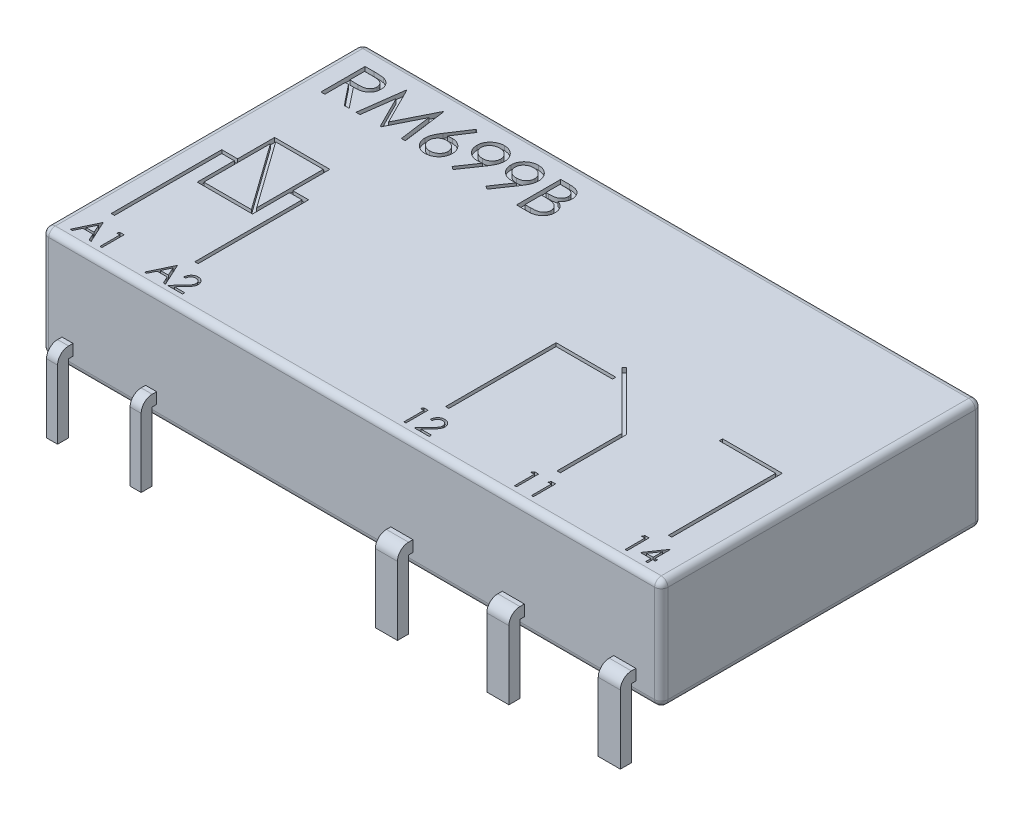
from build123d import *

# Parameters (mm, degrees)
SKETCH2_W             = 28
SKETCH2_H             = 14.5
BOSS_EXTRUDE1_DEPTH   = 5
SKETCH4_W             = 0.5
SKETCH4_H             = 0.5
BOSS_EXTRUDE2_DEPTH   = 3.1
BOSS_EXTRUDE2_2_DEPTH = 3.1
SKETCH4_W_2           = 1
BOSS_EXTRUDE2_3_DEPTH = 3.1
BOSS_EXTRUDE2_4_DEPTH = 3.1
BOSS_EXTRUDE2_5_DEPTH = 3.1
FILLET3_R             = 0.3
CUT_EXTRUDE1_DEPTH    = 0.2
CUT_EXTRUDE2_DEPTH    = 0.2
SKETCH8_W             = 1
SKETCH8_H             = 0.5
SKETCH8_W_2           = 0.5
BOSS_EXTRUDE3_DEPTH   = 0.7
FILLET4_R             = 0.5


with BuildPart() as part:
    # Sketch2 → Boss-Extrude1 (new body)
    with BuildSketch(Plane(origin=(0, 0, 0), x_dir=(1, 0, 0), z_dir=(0, 1, 0))):
        with Locations((0, 7.7)):
            Rectangle(SKETCH2_W, SKETCH2_H)
    extrude(amount=BOSS_EXTRUDE1_DEPTH)

    # Fillet3
    fillet3_edges = [part.edges().sort_by_distance(p)[0] for p in [
        (14, 5, -7.7),
        (0, 5, -14.95),
        (-14, 5, -7.7),
        (0, 0, -14.95),
        (14, 0, -7.7),
        (0, 0, -0.45),
        (-14, 0, -7.7),
        (0, 5, -0.45),
        (-14, 2.5, -14.95),
        (14, 2.5, -14.95),
        (14, 2.5, -0.45),
        (-14, 2.5, -0.45),
    ]]
    fillet(fillet3_edges, radius=FILLET3_R)

    # Sketch6 → Cut-Extrude1 (cut)
    with BuildSketch(Plane(origin=(0, 5, 0), x_dir=(1, 0, 0), z_dir=(0, 1, 0))):
        Polygon((-12.74882859, 1.958392306), (-12.287290129, 0.958392306), (-12.384846219, 0.958392306), (-12.532682757, 1.278905127), (-12.986008077, 1.278905127), (-13.138051347, 0.958392306), (-13.236008077, 0.958392306), (-12.761649103, 1.958392306), align=None)
        Polygon((-12.756240449, 1.763480447), (-12.937330193, 1.381469229), (-12.579958398, 1.381469229), align=None, mode=Mode.SUBTRACT)
        Polygon((-11.985006475, 1.958392306), (-11.800110642, 1.958392306), (-11.800110642, 0.958392306), (-11.889854231, 0.958392306), (-11.889854231, 1.855828204), (-12.043700385, 1.855828204), align=None)
        Polygon((-9.389854231, 1.958392306), (-8.92831577, 0.958392306), (-9.02587186, 0.958392306), (-9.173708398, 1.278905127), (-9.627033719, 1.278905127), (-9.779076988, 0.958392306), (-9.877033719, 0.958392306), (-9.402674744, 1.958392306), align=None)
        Polygon((-9.39726609, 1.763480447), (-9.578355834, 1.381469229), (-9.220984039, 1.381469229), align=None, mode=Mode.SUBTRACT)
        with BuildLine():
            Line((-8.710367052, 1.650699998), (-8.800110642, 1.650699998))
            add(Edge.make_bspline(
                [(-8.800110642, 1.650699998), (-8.799525741, 1.662605966), (-8.798377011, 1.685988971), (-8.7929975, 1.720081515), (-8.785300106, 1.752668601), (-8.774416834, 1.783488576), (-8.760900754, 1.812813949), (-8.744692175, 1.84052824), (-8.725493932, 1.866525722), (-8.70372058, 1.890565392), (-8.680072397, 1.912618983), (-8.654556414, 1.931663338), (-8.627743549, 1.947754102), (-8.59971515, 1.961205885), (-8.570154989, 1.971302984), (-8.539331315, 1.978794881), (-8.507108704, 1.983302408), (-8.485154412, 1.983786918), (-8.473988847, 1.984033332)],
                knots=[0, 0, 0, 0, 3.5738e-05, 7.0188e-05, 0.000103373, 0.000136064, 0.000168061, 0.000200116, 0.000232208, 0.000264831, 0.000297294, 0.000329065, 0.000360156, 0.00039098, 0.000422149, 0.000453681, 0.000486034, 0.000519517, 0.000519517, 0.000519517, 0.000519517], degree=3))
            add(Edge.make_bspline(
                [(-8.473988847, 1.984033332), (-8.463023683, 1.98377663), (-8.441477527, 1.98327222), (-8.410031237, 1.978940497), (-8.380094867, 1.972156043), (-8.351726934, 1.962637352), (-8.325153773, 1.949841802), (-8.30017576, 1.934471076), (-8.276495528, 1.916693982), (-8.255179305, 1.895764321), (-8.235605568, 1.873420782), (-8.218719209, 1.849567095), (-8.204258305, 1.824930157), (-8.192204682, 1.799322099), (-8.1833315, 1.772501805), (-8.176594869, 1.744859747), (-8.172787036, 1.716109801), (-8.17220263, 1.696650785), (-8.171905513, 1.686757691)],
                knots=[0, 0, 0, 0, 3.2882e-05, 6.4613e-05, 9.5033e-05, 0.00012487, 0.000154169, 0.000183303, 0.000212751, 0.000242786, 0.000272749, 0.000301764, 0.000330315, 0.000358367, 0.000386493, 0.000414917, 0.000443616, 0.000473296, 0.000473296, 0.000473296, 0.000473296], degree=3))
            add(Edge.make_bspline(
                [(-8.171905513, 1.686757691), (-8.172389303, 1.672829738), (-8.173348392, 1.645218248), (-8.181552499, 1.604642573), (-8.194365788, 1.565330168), (-8.209793604, 1.533690939), (-8.22535716, 1.508195655), (-8.239382162, 1.487204596), (-8.255800679, 1.464603034), (-8.274851679, 1.440466652), (-8.296141071, 1.414606393), (-8.319861689, 1.38703788), (-8.346182684, 1.358045946), (-8.364656541, 1.338244346), (-8.374229231, 1.327983652)],
                knots=[0, 0, 0, 0, 4.1748e-05, 8.2763e-05, 0.000123686, 0.000165526, 0.000187994, 0.000213273, 0.000241241, 0.000271777, 0.000305505, 0.000341726, 0.000380871, 0.000422969, 0.000422969, 0.000422969, 0.000422969], degree=3))
            Line((-8.374229231, 1.327983652), (-8.624429552, 1.060956409))
            Line((-8.624429552, 1.060956409), (-8.159085001, 1.060956409))
            Line((-8.159085001, 1.060956409), (-8.159085001, 0.958392306))
            Line((-8.159085001, 0.958392306), (-8.83857218, 0.958392306))
            Line((-8.83857218, 0.958392306), (-8.450751667, 1.372254486))
            add(Edge.make_bspline(
                [(-8.450751667, 1.372254486), (-8.441309414, 1.382111145), (-8.423172778, 1.401043769), (-8.397520613, 1.428684615), (-8.374480902, 1.454327341), (-8.353904504, 1.477923498), (-8.336237788, 1.499818231), (-8.320560007, 1.519302432), (-8.30799841, 1.537232275), (-8.29436544, 1.558015308), (-8.281161445, 1.583390256), (-8.269815058, 1.614399881), (-8.26289653, 1.646321953), (-8.262066577, 1.667893964), (-8.261649103, 1.67874487)],
                knots=[0, 0, 0, 0, 4.0948e-05, 7.8653e-05, 0.000113123, 0.000144368, 0.000172557, 0.000197523, 0.000219366, 0.000238203, 0.000272071, 0.000304896, 0.000337034, 0.00036956, 0.00036956, 0.00036956, 0.00036956], degree=3))
            add(Edge.make_bspline(
                [(-8.261649103, 1.67874487), (-8.261830744, 1.685568127), (-8.262188723, 1.699015456), (-8.265348065, 1.718731387), (-8.270122495, 1.737749905), (-8.276963997, 1.75612951), (-8.285994495, 1.773685411), (-8.296986889, 1.790438977), (-8.309669764, 1.806635824), (-8.324341555, 1.821822481), (-8.340459132, 1.835731396), (-8.357486061, 1.848052564), (-8.375500376, 1.858349452), (-8.394426126, 1.866790452), (-8.414210545, 1.873411989), (-8.434891901, 1.878000155), (-8.456413049, 1.880880864), (-8.471108333, 1.881270628), (-8.478596219, 1.881469229)],
                knots=[0, 0, 0, 0, 2.0457e-05, 4.0317e-05, 5.9751e-05, 7.9211e-05, 9.9011e-05, 0.000118847, 0.000139245, 0.000160638, 0.000182083, 0.000203042, 0.00022359, 0.000244214, 0.000265119, 0.000286064, 0.000307681, 0.00033014, 0.00033014, 0.00033014, 0.00033014], degree=3))
            add(Edge.make_bspline(
                [(-8.478596219, 1.881469229), (-8.486416456, 1.881264934), (-8.501774112, 1.880863733), (-8.524322408, 1.878057257), (-8.54583263, 1.873215589), (-8.566358888, 1.866593682), (-8.585935912, 1.858176953), (-8.604468496, 1.847693598), (-8.621915036, 1.835184028), (-8.638308328, 1.821001012), (-8.653412322, 1.805210269), (-8.666682858, 1.787607422), (-8.678278291, 1.768513875), (-8.688395215, 1.747981146), (-8.696611126, 1.725822924), (-8.702889169, 1.702117865), (-8.70785684, 1.676968899), (-8.709516417, 1.659601732), (-8.710367052, 1.650699998)],
                knots=[0, 0, 0, 0, 2.3459e-05, 4.6069e-05, 6.8036e-05, 8.9512e-05, 0.000110686, 0.000131856, 0.000153256, 0.000174984, 0.000196805, 0.000218681, 0.000240978, 0.000263733, 0.000287249, 0.000311741, 0.000337238, 0.00036405, 0.00036405, 0.00036405, 0.00036405], degree=3))
        make_face()
        Polygon((1.758583269, 1.958392306), (1.943479102, 1.958392306), (1.943479102, 0.958392306), (1.853735512, 0.958392306), (1.853735512, 1.855828204), (1.699889358, 1.855828204), align=None)
        with BuildLine():
            Line((2.443479102, 1.650699998), (2.353735512, 1.650699998))
            add(Edge.make_bspline(
                [(2.353735512, 1.650699998), (2.354320413, 1.662605966), (2.355469143, 1.685988971), (2.360848654, 1.720081515), (2.368546048, 1.752668601), (2.37942932, 1.783488576), (2.392945399, 1.812813949), (2.409153979, 1.84052824), (2.428352222, 1.866525722), (2.450125574, 1.890565392), (2.473773757, 1.912618983), (2.49928974, 1.931663338), (2.526102605, 1.947754102), (2.554131004, 1.961205885), (2.583691165, 1.971302984), (2.614514839, 1.978794881), (2.646737449, 1.983302408), (2.668691741, 1.983786918), (2.679857307, 1.984033332)],
                knots=[0, 0, 0, 0, 3.5738e-05, 7.0188e-05, 0.000103373, 0.000136064, 0.000168061, 0.000200116, 0.000232208, 0.000264831, 0.000297294, 0.000329065, 0.000360156, 0.00039098, 0.000422149, 0.000453681, 0.000486034, 0.000519517, 0.000519517, 0.000519517, 0.000519517], degree=3))
            add(Edge.make_bspline(
                [(2.679857307, 1.984033332), (2.690822471, 1.98377663), (2.712368627, 1.98327222), (2.743814917, 1.978940497), (2.773751286, 1.972156043), (2.80211922, 1.962637352), (2.828692381, 1.949841802), (2.853670394, 1.934471076), (2.877350625, 1.916693982), (2.898666849, 1.895764321), (2.918240586, 1.873420782), (2.935126945, 1.849567095), (2.949587849, 1.824930157), (2.961641472, 1.799322099), (2.970514654, 1.772501805), (2.977251285, 1.744859747), (2.981059117, 1.716109801), (2.981643524, 1.696650785), (2.98194064, 1.686757691)],
                knots=[0, 0, 0, 0, 3.2882e-05, 6.4613e-05, 9.5033e-05, 0.00012487, 0.000154169, 0.000183303, 0.000212751, 0.000242786, 0.000272749, 0.000301764, 0.000330315, 0.000358367, 0.000386493, 0.000414917, 0.000443616, 0.000473296, 0.000473296, 0.000473296, 0.000473296], degree=3))
            add(Edge.make_bspline(
                [(2.98194064, 1.686757691), (2.981456851, 1.672829738), (2.980497762, 1.645218248), (2.972293655, 1.604642573), (2.959480366, 1.565330168), (2.944052549, 1.533690939), (2.928488994, 1.508195655), (2.914463992, 1.487204596), (2.898045474, 1.464603034), (2.878994475, 1.440466652), (2.857705083, 1.414606393), (2.833984465, 1.38703788), (2.80766347, 1.358045946), (2.789189613, 1.338244346), (2.779616923, 1.327983652)],
                knots=[0, 0, 0, 0, 4.1748e-05, 8.2763e-05, 0.000123686, 0.000165526, 0.000187994, 0.000213273, 0.000241241, 0.000271777, 0.000305505, 0.000341726, 0.000380871, 0.000422969, 0.000422969, 0.000422969, 0.000422969], degree=3))
            Line((2.779616923, 1.327983652), (2.529416602, 1.060956409))
            Line((2.529416602, 1.060956409), (2.994761153, 1.060956409))
            Line((2.994761153, 1.060956409), (2.994761153, 0.958392306))
            Line((2.994761153, 0.958392306), (2.315273974, 0.958392306))
            Line((2.315273974, 0.958392306), (2.703094487, 1.372254486))
            add(Edge.make_bspline(
                [(2.703094487, 1.372254486), (2.71253674, 1.382111145), (2.730673376, 1.401043769), (2.756325541, 1.428684615), (2.779365252, 1.454327341), (2.79994165, 1.477923498), (2.817608366, 1.499818231), (2.833286146, 1.519302432), (2.845847744, 1.537232275), (2.859480714, 1.558015308), (2.872684709, 1.583390256), (2.884031096, 1.614399881), (2.890949624, 1.646321953), (2.891779577, 1.667893964), (2.892197051, 1.67874487)],
                knots=[0, 0, 0, 0, 4.0948e-05, 7.8653e-05, 0.000113123, 0.000144368, 0.000172557, 0.000197523, 0.000219366, 0.000238203, 0.000272071, 0.000304896, 0.000337034, 0.00036956, 0.00036956, 0.00036956, 0.00036956], degree=3))
            add(Edge.make_bspline(
                [(2.892197051, 1.67874487), (2.89201541, 1.685568127), (2.891657431, 1.699015456), (2.888498089, 1.718731387), (2.883723659, 1.737749905), (2.876882156, 1.75612951), (2.867851659, 1.773685411), (2.856859265, 1.790438977), (2.84417639, 1.806635824), (2.829504599, 1.821822481), (2.813387021, 1.835731396), (2.796360093, 1.848052564), (2.778345777, 1.858349452), (2.759420028, 1.866790452), (2.739635608, 1.873411989), (2.718954253, 1.878000155), (2.697433105, 1.880880864), (2.682737821, 1.881270628), (2.675249935, 1.881469229)],
                knots=[0, 0, 0, 0, 2.0457e-05, 4.0317e-05, 5.9751e-05, 7.9211e-05, 9.9011e-05, 0.000118847, 0.000139245, 0.000160638, 0.000182083, 0.000203042, 0.00022359, 0.000244214, 0.000265119, 0.000286064, 0.000307681, 0.00033014, 0.00033014, 0.00033014, 0.00033014], degree=3))
            add(Edge.make_bspline(
                [(2.675249935, 1.881469229), (2.667429697, 1.881264934), (2.652072041, 1.880863733), (2.629523746, 1.878057257), (2.608013524, 1.873215589), (2.587487266, 1.866593682), (2.567910242, 1.858176953), (2.549377658, 1.847693598), (2.531931118, 1.835184028), (2.515537825, 1.821001012), (2.500433831, 1.805210269), (2.487163295, 1.787607422), (2.475567863, 1.768513875), (2.465450939, 1.747981146), (2.457235027, 1.725822924), (2.450956985, 1.702117865), (2.445989314, 1.676968899), (2.444329737, 1.659601732), (2.443479102, 1.650699998)],
                knots=[0, 0, 0, 0, 2.3459e-05, 4.6069e-05, 6.8036e-05, 8.9512e-05, 0.000110686, 0.000131856, 0.000153256, 0.000174984, 0.000196805, 0.000218681, 0.000240978, 0.000263733, 0.000287249, 0.000311741, 0.000337238, 0.00036405, 0.00036405, 0.00036405, 0.00036405], degree=3))
        make_face()
        Polygon((6.758583269, 1.958392306), (6.943479102, 1.958392306), (6.943479102, 0.958392306), (6.853735512, 0.958392306), (6.853735512, 1.855828204), (6.699889358, 1.855828204), align=None)
        Polygon((7.527814038, 1.958392306), (7.712709871, 1.958392306), (7.712709871, 0.958392306), (7.622966281, 0.958392306), (7.622966281, 1.855828204), (7.469120128, 1.855828204), align=None)
        Polygon((11.758583269, 1.958392306), (11.943479102, 1.958392306), (11.943479102, 0.958392306), (11.853735512, 0.958392306), (11.853735512, 1.855828204), (11.699889358, 1.855828204), align=None)
        Polygon((12.861147371, 1.984033332), (12.879376538, 1.984033332), (12.879376538, 1.291725639), (12.994761153, 1.291725639), (12.994761153, 1.189161537), (12.879376538, 1.189161537), (12.879376538, 0.958392306), (12.789632948, 0.958392306), (12.789632948, 1.189161537), (12.315273974, 1.189161537), align=None)
        Polygon((12.789632948, 1.291725639), (12.789632948, 1.726020511), (12.491556025, 1.291725639), align=None, mode=Mode.SUBTRACT)
    extrude(amount=-CUT_EXTRUDE1_DEPTH, mode=Mode.SUBTRACT)

    # Sketch7 → Cut-Extrude2 (cut)
    with BuildSketch(Plane(origin=(0, 5, 0), x_dir=(1, 0, 0), z_dir=(0, 1, 0))):
        Polygon((-12.21, 9.175), (-9.71, 9.175), (-9.71, 7.5), (-8.995, 7.5), (-8.995, 2.5), (-9.145, 2.5), (-9.145, 7.35), (-9.71, 7.35), (-9.71, 5.675), (-12.21, 5.675), (-12.21, 7.35), (-12.775, 7.35), (-12.775, 2.5), (-12.925, 2.5), (-12.925, 7.5), (-12.21, 7.5), align=None)
        Polygon((-12.06, 8.835965121), (-9.909310628, 5.825), (-12.06, 5.825), align=None, mode=Mode.SUBTRACT)
        Polygon((-12.010689372, 9.025), (-9.86, 9.025), (-9.86, 6.014034879), align=None, mode=Mode.SUBTRACT)
        Polygon((2.195, 2.5), (2.195, 7.5), (4.895, 7.5), (4.895, 7.35), (2.345, 7.35), (2.345, 2.5), align=None)
        Polygon((12.275, 2.5), (12.275, 7.35), (9.725, 7.35), (9.725, 7.5), (12.425, 7.5), (12.425, 2.5), align=None)
        Polygon((7.235, 2.5), (7.235, 5.437867966), (4.662638892, 8.010229073), (4.76870491, 8.11629509), (7.385, 5.5), (7.385, 2.5), align=None)
        with BuildLine():
            Line((-12.943589744, 14), (-12.543349359, 14))
            add(Edge.make_bspline(
                [(-12.543349359, 14), (-12.516640143, 13.999911094), (-12.465355489, 13.999740384), (-12.391885049, 13.998788519), (-12.325126707, 13.996060316), (-12.265115371, 13.993712554), (-12.211852139, 13.989431445), (-12.165173687, 13.985339646), (-12.125295003, 13.979983269), (-12.101154517, 13.975008741), (-12.090224359, 13.97275641)],
                knots=[0, 0, 0, 0, 8.0129e-05, 0.000153857, 0.000220407, 0.000280568, 0.000334004, 0.000380687, 0.000421142, 0.000454614, 0.000454614, 0.000454614, 0.000454614], degree=3))
            add(Edge.make_bspline(
                [(-12.090224359, 13.97275641), (-12.075592002, 13.969141116), (-12.046639437, 13.961987651), (-12.004953685, 13.946867879), (-11.965231214, 13.929370951), (-11.927637029, 13.908820253), (-11.892359434, 13.885063236), (-11.859034685, 13.858510023), (-11.827511563, 13.829305906), (-11.799064917, 13.796714568), (-11.772242602, 13.762522277), (-11.749620529, 13.725548701), (-11.730119684, 13.686884971), (-11.714593674, 13.646137875), (-11.702091975, 13.603702577), (-11.693276981, 13.559194693), (-11.687990588, 13.512816993), (-11.687452385, 13.481183903), (-11.687179487, 13.465144231)],
                knots=[0, 0, 0, 0, 4.5189e-05, 8.9414e-05, 0.000132818, 0.000175313, 0.00021776, 0.000260245, 0.000303046, 0.000346465, 0.000389898, 0.000433258, 0.000476259, 0.000519636, 0.000563882, 0.000608826, 0.000655591, 0.000703695, 0.000703695, 0.000703695, 0.000703695], degree=3))
            add(Edge.make_bspline(
                [(-11.687179487, 13.465144231), (-11.688018915, 13.4384956), (-11.689656855, 13.386497218), (-11.704928343, 13.311033857), (-11.729943497, 13.240639963), (-11.764413948, 13.17540417), (-11.808310791, 13.116598087), (-11.861067815, 13.064946398), (-11.92271445, 13.021723591), (-11.98010263, 12.99175056), (-12.030796459, 12.972554612), (-12.07252978, 12.959048121), (-12.118053767, 12.948612712), (-12.166932244, 12.939264066), (-12.219368619, 12.932205955), (-12.275237213, 12.927036472), (-12.334577871, 12.923805587), (-12.375343053, 12.923324441), (-12.396314103, 12.923076923)],
                knots=[0, 0, 0, 0, 7.9872e-05, 0.000155852, 0.000229857, 0.000303339, 0.000376336, 0.000449148, 0.000523852, 0.000601441, 0.00064266, 0.000686374, 0.000732921, 0.00078266, 0.000835638, 0.00089157, 0.000950951, 0.001013863, 0.001013863, 0.001013863, 0.001013863], degree=3))
            Line((-12.396314103, 12.923076923), (-11.661538462, 12))
            Line((-11.661538462, 12), (-11.88349359, 12))
            Line((-11.88349359, 12), (-12.618269231, 12.923076923))
            Line((-12.618269231, 12.923076923), (-12.764102564, 12.923076923))
            Line((-12.764102564, 12.923076923), (-12.764102564, 12))
            Line((-12.764102564, 12), (-12.943589744, 12))
            Line((-12.943589744, 12), (-12.943589744, 14))
        make_face()
        with BuildLine():
            Line((-12.764102564, 13.794871795), (-12.764102564, 13.128205128))
            Line((-12.764102564, 13.128205128), (-12.397916667, 13.125400641))
            add(Edge.make_bspline(
                [(-12.397916667, 13.125400641), (-12.380819502, 13.125393077), (-12.347680326, 13.125378416), (-12.299737089, 13.127660574), (-12.255097025, 13.130256756), (-12.213930881, 13.134227811), (-12.176220267, 13.139345566), (-12.141984031, 13.145747271), (-12.111166287, 13.153205593), (-12.075224265, 13.164749379), (-12.035089104, 13.183038532), (-11.991471127, 13.209647389), (-11.954326934, 13.243115457), (-11.922945298, 13.281386003), (-11.89772848, 13.32346386), (-11.879950163, 13.368844642), (-11.868668768, 13.416382698), (-11.86733817, 13.449055902), (-11.866666667, 13.465544872)],
                knots=[0, 0, 0, 0, 5.1284e-05, 9.9402e-05, 0.000143962, 0.000185422, 0.000223441, 0.000258093, 0.000289868, 0.000318502, 0.000371222, 0.000421801, 0.000471176, 0.000520422, 0.000569825, 0.000617663, 0.00066616, 0.000715571, 0.000715571, 0.000715571, 0.000715571], degree=3))
            add(Edge.make_bspline(
                [(-11.866666667, 13.465544872), (-11.867353593, 13.481628628), (-11.86871483, 13.513500765), (-11.879828412, 13.560161285), (-11.898622345, 13.604199542), (-11.923949338, 13.645436391), (-11.954805998, 13.68286824), (-11.990987605, 13.714895184), (-12.031504859, 13.74132345), (-12.069374115, 13.758211667), (-12.103222237, 13.768565869), (-12.132610614, 13.775852248), (-12.165817173, 13.781706231), (-12.203003149, 13.786396551), (-12.244009795, 13.790427948), (-12.289044453, 13.79314325), (-12.337808327, 13.794751172), (-12.371606574, 13.794830652), (-12.389102564, 13.794871795)],
                knots=[0, 0, 0, 0, 4.8212e-05, 9.5538e-05, 0.000142938, 0.000191311, 0.000240248, 0.000287926, 0.00033571, 0.00038485, 0.000411714, 0.000441837, 0.000475629, 0.0005128, 0.00055426, 0.00059922, 0.000648124, 0.00070061, 0.00070061, 0.00070061, 0.00070061], degree=3))
            Line((-12.389102564, 13.794871795), (-12.764102564, 13.794871795))
        make_face(mode=Mode.SUBTRACT)
        Polygon((-11.353846154, 12), (-11.089823718, 14), (-11.064182692, 14), (-10.238461538, 12.358974359), (-9.41474359, 14), (-9.388701923, 14), (-9.123076923, 12), (-9.303365385, 12), (-9.494871795, 13.439102564), (-10.216826923, 12), (-10.257291667, 12), (-10.982051282, 13.442307692), (-11.173157051, 12), align=None)
        with BuildLine():
            Line((-7.969230769, 14.051282051), (-7.831009615, 13.942708333))
            Line((-7.831009615, 13.942708333), (-8.359455128, 13.134615385))
            add(Edge.make_bspline(
                [(-8.359455128, 13.134615385), (-8.324272113, 13.140223305), (-8.255643663, 13.151162188), (-8.186177435, 13.152966728), (-8.152323718, 13.153846154)],
                knots=[0, 0, 0, 0, 0.000106748, 0.000208224, 0.000208224, 0.000208224, 0.000208224], degree=3))
            add(Edge.make_bspline(
                [(-8.152323718, 13.153846154), (-8.131996577, 13.153299804), (-8.091983205, 13.152224331), (-8.033236461, 13.143947845), (-7.976785641, 13.130904924), (-7.92286472, 13.111892207), (-7.871280158, 13.087605147), (-7.821735932, 13.058497221), (-7.775163355, 13.023065404), (-7.730962681, 12.983485429), (-7.690832911, 12.939647152), (-7.655303737, 12.893132103), (-7.625459856, 12.843988742), (-7.601246186, 12.792241962), (-7.582443398, 12.737971527), (-7.568736173, 12.681246876), (-7.560633548, 12.622028893), (-7.559533268, 12.58175565), (-7.558974359, 12.561298077)],
                knots=[0, 0, 0, 0, 6.0962e-05, 0.000120002, 0.000177629, 0.000234521, 0.000291158, 0.000348462, 0.000406555, 0.000466412, 0.000526241, 0.000584576, 0.000641742, 0.000698379, 0.00075565, 0.000813759, 0.000873196, 0.000934558, 0.000934558, 0.000934558, 0.000934558], degree=3))
            add(Edge.make_bspline(
                [(-7.558974359, 12.561298077), (-7.559787562, 12.533309675), (-7.561387752, 12.478235123), (-7.577332779, 12.398019862), (-7.602109719, 12.321601282), (-7.637525449, 12.250199469), (-7.681515382, 12.183912287), (-7.735159721, 12.125177735), (-7.796556, 12.072794857), (-7.865977027, 12.028991074), (-7.940687293, 11.993217902), (-8.019174148, 11.967523478), (-8.100675375, 11.951704353), (-8.155992294, 11.949721151), (-8.183974359, 11.948717949)],
                knots=[0, 0, 0, 0, 8.3872e-05, 0.00016504, 0.000244351, 0.000324263, 0.00040338, 0.000482236, 0.000562108, 0.000644796, 0.000727769, 0.000809994, 0.000891949, 0.000975845, 0.000975845, 0.000975845, 0.000975845], degree=3))
            add(Edge.make_bspline(
                [(-8.183974359, 11.948717949), (-8.210886759, 11.949591209), (-8.264195512, 11.951320985), (-8.342614252, 11.966730093), (-8.417964548, 11.99170558), (-8.48971848, 12.026113739), (-8.556187401, 12.069575386), (-8.615653479, 12.121896689), (-8.667820208, 12.18195924), (-8.711234277, 12.249753724), (-8.745667838, 12.322605129), (-8.771490652, 12.398569218), (-8.78657422, 12.477369208), (-8.788681966, 12.530787001), (-8.78974359, 12.557692308)],
                knots=[0, 0, 0, 0, 8.0672e-05, 0.000159798, 0.000238728, 0.00031829, 0.000397853, 0.000476208, 0.000555168, 0.000635738, 0.000716919, 0.000796356, 0.000875875, 0.000956572, 0.000956572, 0.000956572, 0.000956572], degree=3))
            add(Edge.make_bspline(
                [(-8.78974359, 12.557692308), (-8.789068478, 12.578289212), (-8.78769003, 12.620344156), (-8.778065235, 12.684037887), (-8.762599638, 12.749209933), (-8.745279497, 12.804498044), (-8.726979149, 12.849790342), (-8.711749126, 12.886306623), (-8.692792557, 12.923884379), (-8.672579196, 12.963812171), (-8.649289557, 13.005060989), (-8.623966329, 13.048320229), (-8.595909385, 13.092901902), (-8.576240721, 13.123155728), (-8.566185897, 13.138621795)],
                knots=[0, 0, 0, 0, 6.1782e-05, 0.000126147, 0.000192812, 0.000262626, 0.000299676, 0.000339342, 0.00038127, 0.000425887, 0.000473595, 0.000523342, 0.000576257, 0.000631599, 0.000631599, 0.000631599, 0.000631599], degree=3))
            Line((-8.566185897, 13.138621795), (-7.969230769, 14.051282051))
        make_face()
        with BuildLine():
            add(Edge.make_bspline(
                [(-8.189983974, 12.948717949), (-8.205219543, 12.948273352), (-8.234979034, 12.947404926), (-8.278640414, 12.942361925), (-8.319962272, 12.932865316), (-8.359492062, 12.92077027), (-8.39649075, 12.90413995), (-8.43122723, 12.883938922), (-8.463835831, 12.860155391), (-8.493975003, 12.833126299), (-8.521300525, 12.803533138), (-8.5448326, 12.771836268), (-8.565131114, 12.73879958), (-8.581635011, 12.704147042), (-8.594486483, 12.667891899), (-8.603782626, 12.6302009), (-8.608956198, 12.590821296), (-8.609816902, 12.564117009), (-8.61025641, 12.550480769)],
                knots=[0, 0, 0, 0, 4.5717e-05, 8.9299e-05, 0.000131581, 0.000172761, 0.000213115, 0.00025297, 0.000293118, 0.000333976, 0.00037424, 0.000413743, 0.000452221, 0.000490392, 0.000528661, 0.000567432, 0.000606641, 0.000647556, 0.000647556, 0.000647556, 0.000647556], degree=3))
            add(Edge.make_bspline(
                [(-8.61025641, 12.550480769), (-8.609898489, 12.536966495), (-8.60919666, 12.510467015), (-8.602823906, 12.471416055), (-8.593089573, 12.433836108), (-8.578609347, 12.397920908), (-8.561336839, 12.363123012), (-8.538533797, 12.330702849), (-8.513267062, 12.298691381), (-8.483064814, 12.269547683), (-8.450651464, 12.242429612), (-8.416022206, 12.21872661), (-8.3799308, 12.198448796), (-8.341889987, 12.182556741), (-8.302439482, 12.169514291), (-8.261250594, 12.160336303), (-8.218294677, 12.155147431), (-8.189196426, 12.154285606), (-8.174358974, 12.153846154)],
                knots=[0, 0, 0, 0, 4.0514e-05, 7.9443e-05, 0.000118412, 0.000156727, 0.00019543, 0.000234656, 0.00027539, 0.000317602, 0.000360281, 0.000402065, 0.000443313, 0.000484241, 0.000525544, 0.000567827, 0.000610613, 0.000655129, 0.000655129, 0.000655129, 0.000655129], degree=3))
            add(Edge.make_bspline(
                [(-8.174358974, 12.153846154), (-8.159521547, 12.15428564), (-8.130423344, 12.155147533), (-8.087467081, 12.160335915), (-8.04627947, 12.169515714), (-8.006824323, 12.182551583), (-7.968800648, 12.198467931), (-7.932740807, 12.218600456), (-7.898439039, 12.242575381), (-7.866004411, 12.26950134), (-7.835927875, 12.298857255), (-7.810055144, 12.330417097), (-7.787950439, 12.363385037), (-7.769988046, 12.397783831), (-7.755667309, 12.433857824), (-7.745883613, 12.471410238), (-7.739524019, 12.510468538), (-7.738820382, 12.536967009), (-7.738461538, 12.550480769)],
                knots=[0, 0, 0, 0, 4.4516e-05, 8.7302e-05, 0.000129585, 0.000170888, 0.000211816, 0.000253064, 0.000294519, 0.000337198, 0.00037941, 0.000420397, 0.000459399, 0.000498286, 0.000536601, 0.000575571, 0.000614499, 0.000655013, 0.000655013, 0.000655013, 0.000655013], degree=3))
            add(Edge.make_bspline(
                [(-7.738461538, 12.550480769), (-7.738775992, 12.564134798), (-7.739393161, 12.590933217), (-7.746373703, 12.630183284), (-7.756055059, 12.668083402), (-7.770673934, 12.704395373), (-7.789666245, 12.738975903), (-7.812799621, 12.771999675), (-7.83956109, 12.803719873), (-7.870473969, 12.833184335), (-7.904125532, 12.860125523), (-7.939905866, 12.883908126), (-7.977338994, 12.903979542), (-8.016386961, 12.920726457), (-8.05749718, 12.932811871), (-8.100005945, 12.94232801), (-8.144456941, 12.94739202), (-8.174615003, 12.948270343), (-8.189983974, 12.948717949)],
                knots=[0, 0, 0, 0, 4.0914e-05, 8.0302e-05, 0.000119271, 0.000158107, 0.000197371, 0.000237381, 0.000278882, 0.000321668, 0.000365279, 0.00040806, 0.000450363, 0.000492554, 0.000535265, 0.000578721, 0.000623098, 0.000669216, 0.000669216, 0.000669216, 0.000669216], degree=3))
        make_face(mode=Mode.SUBTRACT)
        with BuildLine():
            Line((-6.917948718, 11.948717949), (-7.061378205, 12.048477564))
            Line((-7.061378205, 12.048477564), (-6.505288462, 12.861378205))
            add(Edge.make_bspline(
                [(-6.505288462, 12.861378205), (-6.540768882, 12.857039312), (-6.610631808, 12.848495789), (-6.680995866, 12.846926272), (-6.715625, 12.846153846)],
                knots=[0, 0, 0, 0, 0.000107159, 0.000211003, 0.000211003, 0.000211003, 0.000211003], degree=3))
            add(Edge.make_bspline(
                [(-6.715625, 12.846153846), (-6.736620456, 12.846691604), (-6.7778327, 12.847747176), (-6.838422216, 12.856113924), (-6.896642536, 12.868999711), (-6.952339311, 12.888227571), (-7.005721885, 12.91212369), (-7.056673721, 12.94175627), (-7.10512623, 12.976617008), (-7.150559036, 13.016521574), (-7.191880029, 13.060337604), (-7.228693342, 13.106712257), (-7.259288275, 13.156184241), (-7.284703466, 13.207744366), (-7.303978011, 13.262133709), (-7.318013747, 13.318733367), (-7.326655093, 13.377940019), (-7.327683147, 13.418240094), (-7.328205128, 13.438701923)],
                knots=[0, 0, 0, 0, 6.2963e-05, 0.000123591, 0.00018317, 0.000241577, 0.000300033, 0.000358374, 0.000418082, 0.000478837, 0.000539486, 0.000598554, 0.000656141, 0.000713658, 0.000770684, 0.000828889, 0.000888381, 0.000949743, 0.000949743, 0.000949743, 0.000949743], degree=3))
            add(Edge.make_bspline(
                [(-7.328205128, 13.438701923), (-7.327214023, 13.46668401), (-7.325268683, 13.521607171), (-7.309612388, 13.601855039), (-7.283863623, 13.677733064), (-7.247961693, 13.749041746), (-7.202741852, 13.814755312), (-7.148394086, 13.873960231), (-7.085248964, 13.925814433), (-7.014744953, 13.970388192), (-6.938543227, 14.006236762), (-6.858732565, 14.032659219), (-6.775924496, 14.048201361), (-6.719828685, 14.050250424), (-6.691586538, 14.051282051)],
                knots=[0, 0, 0, 0, 8.3896e-05, 0.00016467, 0.000244236, 0.000323609, 0.000403401, 0.000482797, 0.000563898, 0.000647816, 0.000732408, 0.0008159, 0.00089943, 0.000984126, 0.000984126, 0.000984126, 0.000984126], degree=3))
            add(Edge.make_bspline(
                [(-6.691586538, 14.051282051), (-6.66387887, 14.050236244), (-6.609131129, 14.048169827), (-6.528623125, 14.03303613), (-6.451513973, 14.00752946), (-6.378231123, 13.972281138), (-6.310380031, 13.928097762), (-6.249365281, 13.875449463), (-6.196579259, 13.814303447), (-6.15210847, 13.746138596), (-6.116411304, 13.672900321), (-6.090655714, 13.596452365), (-6.074801063, 13.517344524), (-6.072803162, 13.463747682), (-6.071794872, 13.436698718)],
                knots=[0, 0, 0, 0, 8.3096e-05, 0.00016419, 0.000244768, 0.000326121, 0.000407463, 0.000486988, 0.000567079, 0.000648975, 0.000730503, 0.000810828, 0.000890422, 0.000971519, 0.000971519, 0.000971519, 0.000971519], degree=3))
            add(Edge.make_bspline(
                [(-6.071794872, 13.436698718), (-6.072468248, 13.41570228), (-6.073834024, 13.373116256), (-6.083397628, 13.308413203), (-6.099637734, 13.242441072), (-6.118067276, 13.18660016), (-6.135857086, 13.140481046), (-6.15260059, 13.104051572), (-6.171178964, 13.065707993), (-6.19284683, 13.025852371), (-6.216139571, 12.983976637), (-6.242459157, 12.940500799), (-6.271205198, 12.895366518), (-6.291679324, 12.86493961), (-6.302163462, 12.849358974)],
                knots=[0, 0, 0, 0, 6.2982e-05, 0.000127744, 0.000195764, 0.000266587, 0.00030401, 0.000343998, 0.000386822, 0.000431811, 0.000480065, 0.000530566, 0.000584248, 0.000640584, 0.000640584, 0.000640584, 0.000640584], degree=3))
            Line((-6.302163462, 12.849358974), (-6.917948718, 11.948717949))
        make_face()
        with BuildLine():
            add(Edge.make_bspline(
                [(-6.682371795, 13.051282051), (-6.666466644, 13.051716556), (-6.635504722, 13.05256239), (-6.590146266, 13.057710528), (-6.547332435, 13.06683852), (-6.506948864, 13.079935498), (-6.468590634, 13.095739309), (-6.432867018, 13.115860444), (-6.399748118, 13.13986995), (-6.36901216, 13.166847102), (-6.341718446, 13.196818864), (-6.317408142, 13.228188639), (-6.296744961, 13.26109413), (-6.280423088, 13.295947423), (-6.267003331, 13.331900114), (-6.257735896, 13.369531174), (-6.252601991, 13.408644546), (-6.251726805, 13.435215207), (-6.251282051, 13.448717949)],
                knots=[0, 0, 0, 0, 4.7718e-05, 9.2891e-05, 0.000136739, 0.000178805, 0.000220102, 0.000261, 0.000301473, 0.00034263, 0.00038346, 0.000422886, 0.000461574, 0.000499745, 0.00053815, 0.000576532, 0.000615742, 0.000656256, 0.000656256, 0.000656256, 0.000656256], degree=3))
            add(Edge.make_bspline(
                [(-6.251282051, 13.448717949), (-6.251664719, 13.462226329), (-6.252418814, 13.488846249), (-6.258468699, 13.528017529), (-6.269111684, 13.565556535), (-6.283391961, 13.601668781), (-6.302203525, 13.636057565), (-6.324776946, 13.669154634), (-6.351595489, 13.700750136), (-6.382454098, 13.730100984), (-6.415730985, 13.757156926), (-6.451194128, 13.781034684), (-6.488551223, 13.801046796), (-6.52757436, 13.817560493), (-6.568344845, 13.830447222), (-6.610838553, 13.839714287), (-6.655270213, 13.844841004), (-6.685430948, 13.845710658), (-6.700801282, 13.846153846)],
                knots=[0, 0, 0, 0, 4.0514e-05, 7.9838e-05, 0.000118527, 0.000157362, 0.000196084, 0.000235866, 0.000277367, 0.000320153, 0.000363452, 0.000405899, 0.000448202, 0.000490393, 0.000532841, 0.000576297, 0.000620674, 0.000666791, 0.000666791, 0.000666791, 0.000666791], degree=3))
            add(Edge.make_bspline(
                [(-6.700801282, 13.846153846), (-6.716037941, 13.845709942), (-6.745932141, 13.844839007), (-6.789968803, 13.839724032), (-6.832175185, 13.830384898), (-6.872827539, 13.817566462), (-6.911849517, 13.801045564), (-6.94920485, 13.781033635), (-6.984676288, 13.757162422), (-7.017921271, 13.730079695), (-7.04883437, 13.700886755), (-7.075191815, 13.669016224), (-7.097816896, 13.636074781), (-7.116602612, 13.601664205), (-7.130889765, 13.565557756), (-7.141530908, 13.528017198), (-7.147581288, 13.488846335), (-7.148335315, 13.462226358), (-7.148717949, 13.448717949)],
                knots=[0, 0, 0, 0, 4.5717e-05, 8.9696e-05, 0.000132761, 0.000175208, 0.000217399, 0.000259703, 0.00030215, 0.000345449, 0.000388235, 0.000429477, 0.00046926, 0.000507982, 0.000546817, 0.000585505, 0.000624829, 0.000665344, 0.000665344, 0.000665344, 0.000665344], degree=3))
            add(Edge.make_bspline(
                [(-7.148717949, 13.448717949), (-7.148371705, 13.435204692), (-7.14768885, 13.408554077), (-7.141101541, 13.369396139), (-7.130085381, 13.331860028), (-7.115331444, 13.295580767), (-7.095901964, 13.260911133), (-7.072059765, 13.228015498), (-7.044113739, 13.196520955), (-7.01243746, 13.166916834), (-6.977769939, 13.139744162), (-6.940743227, 13.116012515), (-6.901994749, 13.095971119), (-6.861388103, 13.079890328), (-6.819224217, 13.066969377), (-6.775124142, 13.057727351), (-6.729233721, 13.05261177), (-6.698142303, 13.051729543), (-6.682371795, 13.051282051)],
                knots=[0, 0, 0, 0, 4.0514e-05, 7.9902e-05, 0.0001187, 0.000157686, 0.000197144, 0.000237617, 0.000279339, 0.000323273, 0.000367513, 0.0004113, 0.000455021, 0.000498172, 0.000542149, 0.000587173, 0.000633142, 0.00068046, 0.00068046, 0.00068046, 0.00068046], degree=3))
        make_face(mode=Mode.SUBTRACT)
        with BuildLine():
            Line((-5.379487179, 11.948717949), (-5.522916667, 12.048477564))
            Line((-5.522916667, 12.048477564), (-4.966826923, 12.861378205))
            add(Edge.make_bspline(
                [(-4.966826923, 12.861378205), (-5.002307343, 12.857039312), (-5.072170269, 12.848495789), (-5.142534328, 12.846926272), (-5.177163462, 12.846153846)],
                knots=[0, 0, 0, 0, 0.000107159, 0.000211003, 0.000211003, 0.000211003, 0.000211003], degree=3))
            add(Edge.make_bspline(
                [(-5.177163462, 12.846153846), (-5.198158917, 12.846691604), (-5.239371161, 12.847747176), (-5.299960677, 12.856113924), (-5.358180997, 12.868999711), (-5.413877772, 12.888227571), (-5.467260346, 12.91212369), (-5.518212183, 12.94175627), (-5.566664691, 12.976617008), (-5.612097497, 13.016521574), (-5.653418491, 13.060337604), (-5.690231804, 13.106712257), (-5.720826736, 13.156184241), (-5.746241928, 13.207744366), (-5.765516473, 13.262133709), (-5.779552209, 13.318733367), (-5.788193554, 13.377940019), (-5.789221609, 13.418240094), (-5.78974359, 13.438701923)],
                knots=[0, 0, 0, 0, 6.2963e-05, 0.000123591, 0.00018317, 0.000241577, 0.000300033, 0.000358374, 0.000418082, 0.000478837, 0.000539486, 0.000598554, 0.000656141, 0.000713658, 0.000770684, 0.000828889, 0.000888381, 0.000949743, 0.000949743, 0.000949743, 0.000949743], degree=3))
            add(Edge.make_bspline(
                [(-5.78974359, 13.438701923), (-5.788752484, 13.46668401), (-5.786807145, 13.521607171), (-5.771150849, 13.601855039), (-5.745402084, 13.677733064), (-5.709500155, 13.749041746), (-5.664280314, 13.814755312), (-5.609932548, 13.873960231), (-5.546787425, 13.925814433), (-5.476283415, 13.970388192), (-5.400081688, 14.006236762), (-5.320271027, 14.032659219), (-5.237462958, 14.048201361), (-5.181367146, 14.050250424), (-5.153125, 14.051282051)],
                knots=[0, 0, 0, 0, 8.3896e-05, 0.00016467, 0.000244236, 0.000323609, 0.000403401, 0.000482797, 0.000563898, 0.000647816, 0.000732408, 0.0008159, 0.00089943, 0.000984126, 0.000984126, 0.000984126, 0.000984126], degree=3))
            add(Edge.make_bspline(
                [(-5.153125, 14.051282051), (-5.125417332, 14.050236244), (-5.070669591, 14.048169827), (-4.990161587, 14.03303613), (-4.913052434, 14.00752946), (-4.839769585, 13.972281138), (-4.771918492, 13.928097762), (-4.710903743, 13.875449463), (-4.65811772, 13.814303447), (-4.613646931, 13.746138596), (-4.577949766, 13.672900321), (-4.552194175, 13.596452365), (-4.536339524, 13.517344524), (-4.534341623, 13.463747682), (-4.533333333, 13.436698718)],
                knots=[0, 0, 0, 0, 8.3096e-05, 0.00016419, 0.000244768, 0.000326121, 0.000407463, 0.000486988, 0.000567079, 0.000648975, 0.000730503, 0.000810828, 0.000890422, 0.000971519, 0.000971519, 0.000971519, 0.000971519], degree=3))
            add(Edge.make_bspline(
                [(-4.533333333, 13.436698718), (-4.53400671, 13.41570228), (-4.535372486, 13.373116256), (-4.54493609, 13.308413203), (-4.561176196, 13.242441072), (-4.579605738, 13.18660016), (-4.597395548, 13.140481046), (-4.614139052, 13.104051572), (-4.632717425, 13.065707993), (-4.654385291, 13.025852371), (-4.677678032, 12.983976637), (-4.703997619, 12.940500799), (-4.73274366, 12.895366518), (-4.753217785, 12.86493961), (-4.763701923, 12.849358974)],
                knots=[0, 0, 0, 0, 6.2982e-05, 0.000127744, 0.000195764, 0.000266587, 0.00030401, 0.000343998, 0.000386822, 0.000431811, 0.000480065, 0.000530566, 0.000584248, 0.000640584, 0.000640584, 0.000640584, 0.000640584], degree=3))
            Line((-4.763701923, 12.849358974), (-5.379487179, 11.948717949))
        make_face()
        with BuildLine():
            add(Edge.make_bspline(
                [(-5.143910256, 13.051282051), (-5.128005105, 13.051716556), (-5.097043184, 13.05256239), (-5.051684727, 13.057710528), (-5.008870897, 13.06683852), (-4.968487326, 13.079935498), (-4.930129096, 13.095739309), (-4.89440548, 13.115860444), (-4.86128658, 13.13986995), (-4.830550621, 13.166847102), (-4.803256907, 13.196818864), (-4.778946604, 13.228188639), (-4.758283423, 13.26109413), (-4.74196155, 13.295947423), (-4.728541793, 13.331900114), (-4.719274357, 13.369531174), (-4.714140452, 13.408644546), (-4.713265267, 13.435215207), (-4.712820513, 13.448717949)],
                knots=[0, 0, 0, 0, 4.7718e-05, 9.2891e-05, 0.000136739, 0.000178805, 0.000220102, 0.000261, 0.000301473, 0.00034263, 0.00038346, 0.000422886, 0.000461574, 0.000499745, 0.00053815, 0.000576532, 0.000615742, 0.000656256, 0.000656256, 0.000656256, 0.000656256], degree=3))
            add(Edge.make_bspline(
                [(-4.712820513, 13.448717949), (-4.713203181, 13.462226329), (-4.713957275, 13.488846249), (-4.720007161, 13.528017529), (-4.730650146, 13.565556535), (-4.744930423, 13.601668781), (-4.763741987, 13.636057565), (-4.786315407, 13.669154634), (-4.81313395, 13.700750136), (-4.843992559, 13.730100984), (-4.877269447, 13.757156926), (-4.91273259, 13.781034684), (-4.950089685, 13.801046796), (-4.989112822, 13.817560493), (-5.029883307, 13.830447222), (-5.072377014, 13.839714287), (-5.116808675, 13.844841004), (-5.14696941, 13.845710658), (-5.162339744, 13.846153846)],
                knots=[0, 0, 0, 0, 4.0514e-05, 7.9838e-05, 0.000118527, 0.000157362, 0.000196084, 0.000235866, 0.000277367, 0.000320153, 0.000363452, 0.000405899, 0.000448202, 0.000490393, 0.000532841, 0.000576297, 0.000620674, 0.000666791, 0.000666791, 0.000666791, 0.000666791], degree=3))
            add(Edge.make_bspline(
                [(-5.162339744, 13.846153846), (-5.177576403, 13.845709942), (-5.207470602, 13.844839007), (-5.251507265, 13.839724032), (-5.293713646, 13.830384898), (-5.334366001, 13.817566462), (-5.373387978, 13.801045564), (-5.410743311, 13.781033635), (-5.446214749, 13.757162422), (-5.479459733, 13.730079695), (-5.510372831, 13.700886755), (-5.536730276, 13.669016224), (-5.559355357, 13.636074781), (-5.578141073, 13.601664205), (-5.592428226, 13.565557756), (-5.60306937, 13.528017198), (-5.60911975, 13.488846335), (-5.609873777, 13.462226358), (-5.61025641, 13.448717949)],
                knots=[0, 0, 0, 0, 4.5717e-05, 8.9696e-05, 0.000132761, 0.000175208, 0.000217399, 0.000259703, 0.00030215, 0.000345449, 0.000388235, 0.000429477, 0.00046926, 0.000507982, 0.000546817, 0.000585505, 0.000624829, 0.000665344, 0.000665344, 0.000665344, 0.000665344], degree=3))
            add(Edge.make_bspline(
                [(-5.61025641, 13.448717949), (-5.609910167, 13.435204692), (-5.609227311, 13.408554077), (-5.602640003, 13.369396139), (-5.591623843, 13.331860028), (-5.576869905, 13.295580767), (-5.557440425, 13.260911133), (-5.533598227, 13.228015498), (-5.5056522, 13.196520955), (-5.473975922, 13.166916834), (-5.439308401, 13.139744162), (-5.402281689, 13.116012515), (-5.363533211, 13.095971119), (-5.322926565, 13.079890328), (-5.280762679, 13.066969377), (-5.236662604, 13.057727351), (-5.190772182, 13.05261177), (-5.159680764, 13.051729543), (-5.143910256, 13.051282051)],
                knots=[0, 0, 0, 0, 4.0514e-05, 7.9902e-05, 0.0001187, 0.000157686, 0.000197144, 0.000237617, 0.000279339, 0.000323273, 0.000367513, 0.0004113, 0.000455021, 0.000498172, 0.000542149, 0.000587173, 0.000633142, 0.00068046, 0.00068046, 0.00068046, 0.00068046], degree=3))
        make_face(mode=Mode.SUBTRACT)
        with BuildLine():
            Line((-4.097435897, 14), (-3.707211538, 14))
            add(Edge.make_bspline(
                [(-3.707211538, 14), (-3.688109551, 13.999899571), (-3.651085145, 13.999704915), (-3.597245464, 13.996685983), (-3.546817572, 13.9925696), (-3.499786845, 13.986038119), (-3.456175015, 13.978157103), (-3.415850651, 13.968613208), (-3.378941981, 13.957169429), (-3.33487756, 13.938971554), (-3.284637183, 13.911929744), (-3.230238101, 13.871970564), (-3.183721393, 13.82309487), (-3.143614926, 13.767961924), (-3.111728572, 13.707312912), (-3.088660402, 13.642593376), (-3.074055902, 13.574638094), (-3.072553939, 13.52798485), (-3.071794872, 13.504407051)],
                knots=[0, 0, 0, 0, 5.7297e-05, 0.000111056, 0.000161729, 0.00020904, 0.000253439, 0.000294641, 0.000333288, 0.000369223, 0.000437521, 0.000503948, 0.000570816, 0.000639094, 0.000707911, 0.000775583, 0.000844728, 0.000915378, 0.000915378, 0.000915378, 0.000915378], degree=3))
            add(Edge.make_bspline(
                [(-3.071794872, 13.504407051), (-3.072419568, 13.482319877), (-3.073647155, 13.438916495), (-3.085385875, 13.375434147), (-3.1037634, 13.315004879), (-3.129309256, 13.257849231), (-3.162510397, 13.205258594), (-3.201858008, 13.156808728), (-3.249330466, 13.114550981), (-3.284898032, 13.090926466), (-3.302964744, 13.078926282)],
                knots=[0, 0, 0, 0, 6.6204e-05, 0.000130097, 0.000192956, 0.000255358, 0.000317276, 0.000379039, 0.000442022, 0.000507042, 0.000507042, 0.000507042, 0.000507042], degree=3))
            add(Edge.make_bspline(
                [(-3.302964744, 13.078926282), (-3.280244499, 13.070203426), (-3.236775044, 13.05351444), (-3.176954465, 13.024008461), (-3.125414554, 12.991915826), (-3.081759042, 12.956869055), (-3.044423239, 12.919092591), (-3.011821558, 12.878032526), (-2.98400363, 12.833153236), (-2.960167674, 12.784922644), (-2.941568384, 12.733833234), (-2.927639296, 12.680364219), (-2.919657897, 12.62470733), (-2.918522102, 12.586829971), (-2.917948718, 12.567708333)],
                knots=[0, 0, 0, 0, 7.2984e-05, 0.000139636, 0.000199771, 0.00025477, 0.00030718, 0.000358801, 0.000411716, 0.000465289, 0.000519919, 0.00057453, 0.000630793, 0.000688153, 0.000688153, 0.000688153, 0.000688153], degree=3))
            add(Edge.make_bspline(
                [(-2.917948718, 12.567708333), (-2.918506916, 12.548184406), (-2.919605185, 12.509770533), (-2.927708026, 12.453339028), (-2.941427516, 12.399410487), (-2.960325314, 12.347636097), (-2.984989494, 12.29811602), (-3.015005473, 12.250794155), (-3.050794938, 12.206145966), (-3.090830863, 12.163675324), (-3.136123518, 12.125488017), (-3.184989664, 12.091479042), (-3.238044704, 12.063509863), (-3.294417272, 12.040014994), (-3.354739738, 12.022068023), (-3.418741228, 12.009512267), (-3.486366543, 12.001052246), (-3.532772115, 12.0003567), (-3.556570513, 12)],
                knots=[0, 0, 0, 0, 5.8561e-05, 0.00011522, 0.000170607, 0.000225237, 0.000280243, 0.00033626, 0.000393011, 0.00045167, 0.000511075, 0.000570418, 0.000629925, 0.000690638, 0.00075338, 0.000818359, 0.000886142, 0.000957497, 0.000957497, 0.000957497, 0.000957497], degree=3))
            Line((-3.556570513, 12), (-4.097435897, 12))
            Line((-4.097435897, 12), (-4.097435897, 14))
        make_face()
        with BuildLine():
            Line((-3.917948718, 13.794871795), (-3.917948718, 13.153846154))
            Line((-3.917948718, 13.153846154), (-3.797355769, 13.153846154))
            add(Edge.make_bspline(
                [(-3.797355769, 13.153846154), (-3.779727886, 13.154074681), (-3.745667224, 13.154516243), (-3.696341569, 13.15578111), (-3.650555844, 13.159322849), (-3.608389082, 13.16286357), (-3.569907686, 13.168620477), (-3.535196908, 13.175473119), (-3.503711995, 13.182720493), (-3.467403683, 13.195045914), (-3.426219141, 13.213261729), (-3.38231451, 13.241531349), (-3.343609099, 13.275202408), (-3.310924992, 13.314054386), (-3.28417558, 13.356835064), (-3.265596314, 13.402861853), (-3.252997866, 13.450987643), (-3.251859848, 13.484026644), (-3.251282051, 13.500801282)],
                knots=[0, 0, 0, 0, 5.2891e-05, 0.000102196, 0.000147981, 0.000190637, 0.000229109, 0.000264624, 0.000296788, 0.000325928, 0.000379543, 0.000431443, 0.000481984, 0.000532872, 0.00058324, 0.000632642, 0.000681325, 0.000731534, 0.000731534, 0.000731534, 0.000731534], degree=3))
            add(Edge.make_bspline(
                [(-3.251282051, 13.500801282), (-3.251582726, 13.511901723), (-3.252172531, 13.53367645), (-3.25700299, 13.565418938), (-3.265213032, 13.595272511), (-3.275758343, 13.623646288), (-3.290494736, 13.64965306), (-3.307845287, 13.674192029), (-3.328808539, 13.696427525), (-3.35266986, 13.717210095), (-3.380103359, 13.73563554), (-3.411092668, 13.751773119), (-3.446057055, 13.764767848), (-3.484407258, 13.776148507), (-3.526733594, 13.784141818), (-3.572547624, 13.790800896), (-3.622224607, 13.794191035), (-3.656593237, 13.794639813), (-3.674358974, 13.794871795)],
                knots=[0, 0, 0, 0, 3.3292e-05, 6.5305e-05, 9.6017e-05, 0.000126075, 0.000155844, 0.000185419, 0.000216036, 0.00024728, 0.000280172, 0.000314936, 0.00035184, 0.000391904, 0.000434805, 0.000480926, 0.000530736, 0.000584035, 0.000584035, 0.000584035, 0.000584035], degree=3))
            Line((-3.674358974, 13.794871795), (-3.917948718, 13.794871795))
        make_face(mode=Mode.SUBTRACT)
        with BuildLine():
            Line((-3.917948718, 12.948717949), (-3.917948718, 12.205128205))
            Line((-3.917948718, 12.205128205), (-3.662339744, 12.205128205))
            add(Edge.make_bspline(
                [(-3.662339744, 12.205128205), (-3.644043214, 12.205347489), (-3.608779067, 12.205770131), (-3.557864078, 12.207149876), (-3.510673733, 12.21028832), (-3.46742337, 12.215228805), (-3.427645968, 12.220587919), (-3.391818709, 12.227794365), (-3.35965117, 12.236050914), (-3.322351566, 12.248813298), (-3.280349561, 12.268639853), (-3.235086215, 12.298533697), (-3.194842661, 12.334147015), (-3.160668228, 12.375364681), (-3.132660806, 12.420182582), (-3.11228626, 12.46769421), (-3.099720056, 12.517114512), (-3.098198816, 12.550809776), (-3.097435897, 12.567708333)],
                knots=[0, 0, 0, 0, 5.4894e-05, 0.0001058, 0.000152785, 0.000196718, 0.00023638, 0.000273152, 0.000306289, 0.000335936, 0.000391315, 0.000445096, 0.000498164, 0.000551923, 0.000605178, 0.000656154, 0.000706489, 0.000757128, 0.000757128, 0.000757128, 0.000757128], degree=3))
            add(Edge.make_bspline(
                [(-3.097435897, 12.567708333), (-3.097593671, 12.578275956), (-3.097906674, 12.599240746), (-3.102627026, 12.630049786), (-3.109492094, 12.659893142), (-3.118367199, 12.688851851), (-3.131292609, 12.716402351), (-3.146382063, 12.743089528), (-3.164074293, 12.768948659), (-3.191642388, 12.801641376), (-3.231740664, 12.83930824), (-3.288715965, 12.876186813), (-3.353500135, 12.905928417), (-3.400487274, 12.918556689), (-3.424759615, 12.925080128)],
                knots=[0, 0, 0, 0, 3.1673e-05, 6.2836e-05, 9.3256e-05, 0.000123538, 0.000153479, 0.000184339, 0.000215455, 0.00024731, 0.000312508, 0.000379624, 0.000450084, 0.000525374, 0.000525374, 0.000525374, 0.000525374], degree=3))
            add(Edge.make_bspline(
                [(-3.424759615, 12.925080128), (-3.434490527, 12.927054462), (-3.455589151, 12.931335225), (-3.489993483, 12.935853912), (-3.529271123, 12.939879661), (-3.573512767, 12.942857465), (-3.62277439, 12.94593549), (-3.677161201, 12.947132531), (-3.736451095, 12.948560679), (-3.777589593, 12.948664185), (-3.798958333, 12.948717949)],
                knots=[0, 0, 0, 0, 2.978e-05, 6.4569e-05, 0.000104035, 0.000148222, 0.000197581, 0.000252092, 0.000311399, 0.000375503, 0.000375503, 0.000375503, 0.000375503], degree=3))
            Line((-3.798958333, 12.948717949), (-3.917948718, 12.948717949))
        make_face(mode=Mode.SUBTRACT)
    extrude(amount=-CUT_EXTRUDE2_DEPTH, mode=Mode.SUBTRACT)



with BuildPart() as body_2:
    # Sketch4 → Boss-Extrude2 (new body)
    with BuildSketch(Plane(origin=(0, 0.6, 0), x_dir=(1, 0, 0), z_dir=(0, 1, 0))):
        with Locations((-12.85, 0)):
            Rectangle(SKETCH4_W, SKETCH4_H)
    extrude(amount=-BOSS_EXTRUDE2_DEPTH)


with BuildPart() as body_3:
    # Sketch4 → Boss-Extrude2 2 (new body)
    with BuildSketch(Plane(origin=(0, 0.6, 0), x_dir=(1, 0, 0), z_dir=(0, 1, 0))):
        with Locations((-9.07, 0)):
            Rectangle(SKETCH4_W, SKETCH4_H)
    extrude(amount=-BOSS_EXTRUDE2_2_DEPTH)


with BuildPart() as body_4:
    # Sketch4 → Boss-Extrude2 3 (new body)
    with BuildSketch(Plane(origin=(0, 0.6, 0), x_dir=(1, 0, 0), z_dir=(0, 1, 0))):
        with Locations((2.27, 0)):
            Rectangle(SKETCH4_W_2, SKETCH4_H)
    extrude(amount=-BOSS_EXTRUDE2_3_DEPTH)


with BuildPart() as body_5:
    # Sketch4 → Boss-Extrude2 4 (new body)
    with BuildSketch(Plane(origin=(0, 0.6, 0), x_dir=(1, 0, 0), z_dir=(0, 1, 0))):
        with Locations((7.31, 0)):
            Rectangle(SKETCH4_W_2, SKETCH4_H)
    extrude(amount=-BOSS_EXTRUDE2_4_DEPTH)


with BuildPart() as body_6:
    # Sketch4 → Boss-Extrude2 5 (new body)
    with BuildSketch(Plane(origin=(0, 0.6, 0), x_dir=(1, 0, 0), z_dir=(0, 1, 0))):
        with Locations((12.35, 0)):
            Rectangle(SKETCH4_W_2, SKETCH4_H)
    extrude(amount=-BOSS_EXTRUDE2_5_DEPTH)


with BuildPart() as part_1:
    add(part.part)

    add(body_2.part)  # Boss-Extrude3 merges body 2

    add(body_3.part)  # Boss-Extrude3 merges body 3

    add(body_4.part)  # Boss-Extrude3 merges body 4

    add(body_5.part)  # Boss-Extrude3 merges body 5

    add(body_6.part)  # Boss-Extrude3 merges body 6
    # Sketch8 → Boss-Extrude3 (add)
    with BuildSketch(Plane.XY.offset(-0.45)):
        with Locations((12.35, 0.85)):
            Rectangle(SKETCH8_W, SKETCH8_H)
        with Locations((7.31, 0.85)):
            Rectangle(SKETCH8_W, SKETCH8_H)
        with Locations((2.27, 0.85)):
            Rectangle(SKETCH8_W, SKETCH8_H)
        with Locations((-9.07, 0.85)):
            Rectangle(SKETCH8_W_2, SKETCH8_H)
        with Locations((-12.85, 0.85)):
            Rectangle(SKETCH8_W_2, SKETCH8_H)
    extrude(amount=BOSS_EXTRUDE3_DEPTH)

    # Fillet4
    fillet4_edges = [part_1.edges().sort_by_distance(p)[0] for p in [
        (12.35, 1.1, 0.25),
        (7.31, 1.1, 0.25),
        (2.27, 1.1, 0.25),
        (-9.07, 1.1, 0.25),
        (-12.85, 1.1, 0.25),
    ]]
    fillet(fillet4_edges, radius=FILLET4_R)


solid = part_1.part
